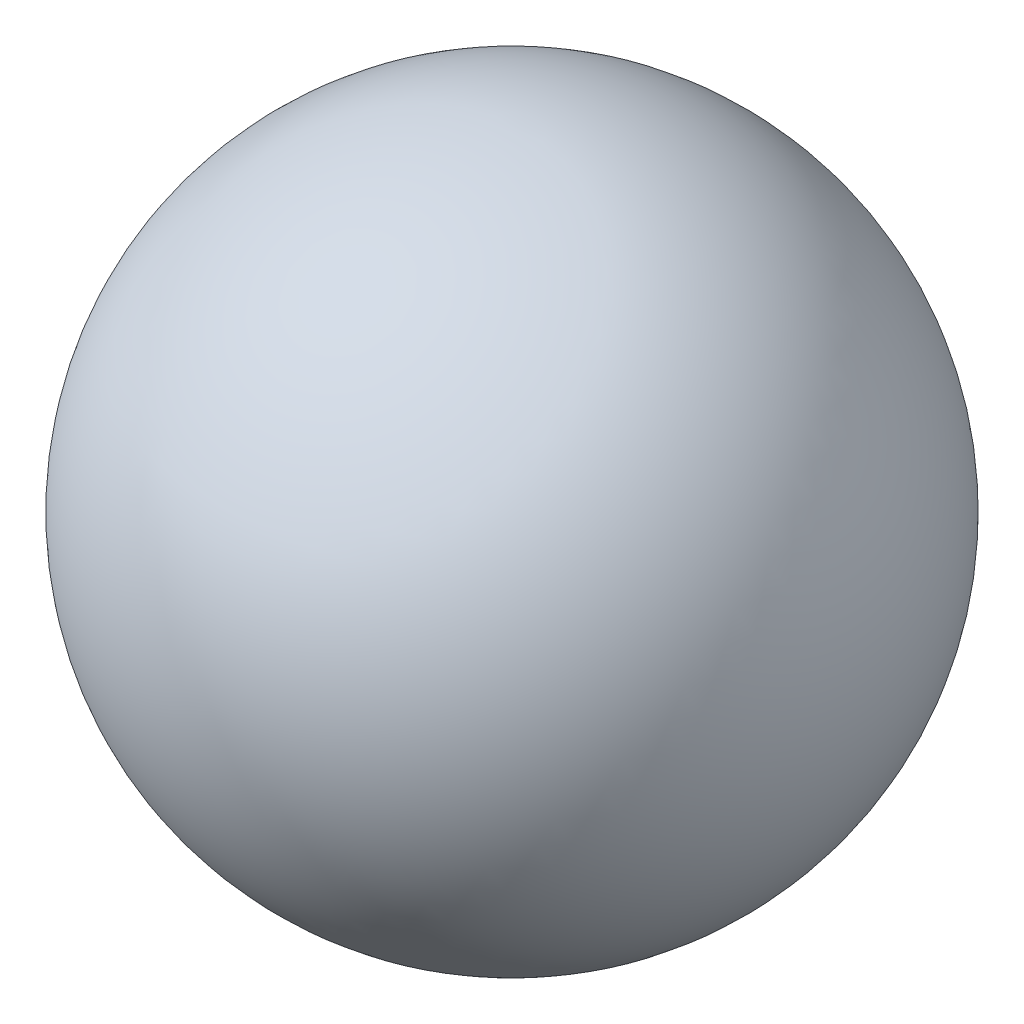
from build123d import *


with BuildPart() as part:
    # Sketch1 → Revolve1 (revolve)
    with BuildSketch(Plane.XY):
        with BuildLine():
            Line((0, 0), (0, 152.4))
            ThreePointArc((0, 152.4), (-76.2, 76.2), (0, 0))
        make_face()
    revolve(axis=Axis((0, 0, 0), (0, 1, 0)))


solid = part.part
